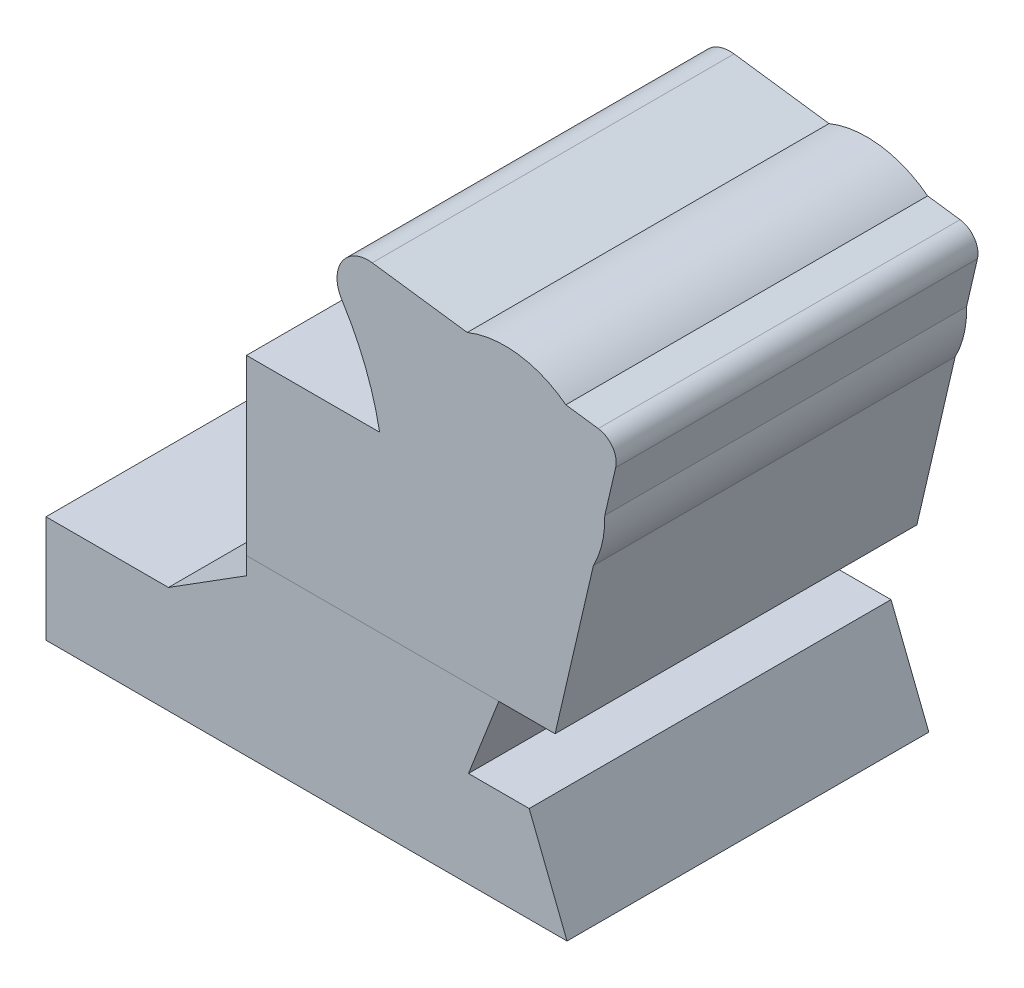
from build123d import *

# Parameters (mm, degrees)
SKETCH_1_R                     = 27.60110162
EXTRUDE_1_DEPTH                = 50
SPLIT_BODIES_1_SURFACE_1_BACK  = 231.64
SPLIT_BODIES_1_SURFACE_1_DEPTH = 463.28
SPLIT_BODIES_1_SURFACE_2_BACK  = 231.64
SPLIT_BODIES_1_SURFACE_2_DEPTH = 463.28


with BuildPart() as part:
    # 草图1 → 凸台-拉伸1 (new, symmetric)
    with BuildSketch(Plane.XY):
        with Locations((126.841, 106.3205)):
            Circle(SKETCH_1_R)
        with BuildLine():
            Line((0, 29.556947787), (33.841128496, 29.556947787))
            Line((33.841128496, 29.556947787), (55.404404979, 43.133825573))
            Line((55.404404979, 43.133825573), (55.404404979, 95.897124924))
            Line((55.404404979, 95.897124924), (92.202864513, 95.897124924))
            ThreePointArc((92.202864513, 95.897124924), (88.266951773, 109.605982584), (81.786119565, 122.311217777))
            ThreePointArc((81.786119565, 122.311217777), (81.790702408, 131.54578908), (90.169806602, 135.427533672))
            Line((90.169806602, 135.427533672), (152.632483554, 126.981321854))
            ThreePointArc((152.632483554, 126.981321854), (156.573746893, 124.561834969), (157.437634447, 120.018579331))
            Line((157.437634447, 120.018579331), (140.698476255, 47.962391292))
            Line((140.698476255, 47.962391292), (125.156200351, 47.962391292))
            Line((125.156200351, 47.962391292), (116.770080258, 26.493923855))
            Line((116.770080258, 26.493923855), (133.542320443, 26.493923855))
            Line((133.542320443, 26.493923855), (144.001, 0))
            Line((144.001, 0), (0, 0))
            Line((0, 0), (0, 29.556947787))
        make_face()
    extrude(amount=EXTRUDE_1_DEPTH, both=True)


with BuildPart() as body_2:
    # Split Bodies 1: the piece behind the surface
    add(part.part)
    # Split Bodies 1 surface: a surface, the sketch's curves swept straight by 463.28 mm
    with BuildLine(Plane.XY.offset(50).offset(-SPLIT_BODIES_1_SURFACE_1_BACK), mode=Mode.PRIVATE) as split_bodies_1_surface_1_path:
        Line((125.156200351, 47.962391292), (37.921543342, 47.962391292))
    split_bodies_1_surface_1 = Shell.extrude(split_bodies_1_surface_1_path.wire(), (0 * SPLIT_BODIES_1_SURFACE_1_DEPTH, 0 * SPLIT_BODIES_1_SURFACE_1_DEPTH, 1 * SPLIT_BODIES_1_SURFACE_1_DEPTH))
    split(bisect_by=split_bodies_1_surface_1, keep=Keep.BOTTOM)


with BuildPart() as part_1:
    add(part.part)

    # Split Bodies 1: split by a surface, the side it looks to stays
    # Split Bodies 1 surface: a surface, the sketch's curves swept straight by 463.28 mm
    with BuildLine(Plane.XY.offset(50).offset(-SPLIT_BODIES_1_SURFACE_2_BACK), mode=Mode.PRIVATE) as split_bodies_1_surface_2_path:
        Line((125.156200351, 47.962391292), (37.921543342, 47.962391292))
    split_bodies_1_surface_2 = Shell.extrude(split_bodies_1_surface_2_path.wire(), (0 * SPLIT_BODIES_1_SURFACE_2_DEPTH, 0 * SPLIT_BODIES_1_SURFACE_2_DEPTH, 1 * SPLIT_BODIES_1_SURFACE_2_DEPTH))
    split(bisect_by=split_bodies_1_surface_2, keep=Keep.TOP)


solid = Compound([body_2.part, part_1.part])
